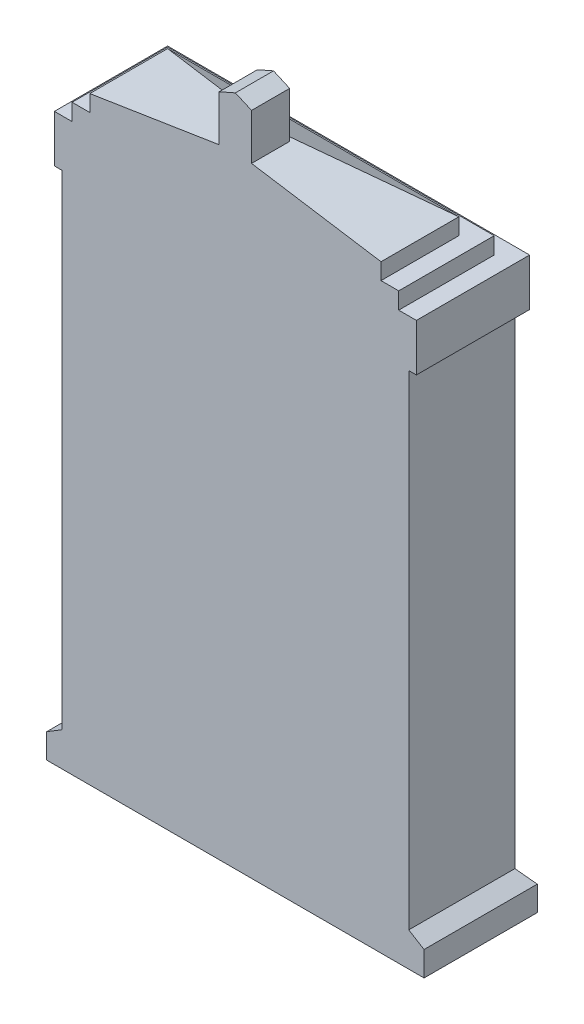
from build123d import *

# Parameters (mm, degrees)
BOSS_EXTRUDE1_DEPTH             = 7.62
SKETCH3_W                       = 9.144
SKETCH3_H                       = 33.984735974
CUT_EXTRUDE3_DEPTH              = 1.27
SKETCH2_W                       = 6.726332881
SKETCH2_H                       = 7.259111723
SKETCH2_H_2                     = 7.259111722
SKETCH2_W_2                     = 1.903444294
SKETCH2_H_3                     = 3.394508427
SKETCH2_W_3                     = 1.903444293
SKETCH2_H_4                     = 3.394508426
CUT_EXTRUDE4_DEPTH              = 2.032
SKETCH5_W                       = 4.686975047
SKETCH5_H                       = 6.157621802
BOSS_EXTRUDE3_DEPTH             = 0.508
SKETCH8_W                       = 27.088929776
SKETCH8_H                       = 1.771956064
BOSS_EXTRUDE4_DEPTH             = 0.508
BOSS_EXTRUDE5_REACH             = 15.544
BOSS_EXTRUDE5_DIRECTION_2_REACH = 15.544
SKETCH10_W                      = 25.989428986
SKETCH10_H                      = 3.393956474
BOSS_EXTRUDE6_DEPTH             = 0.508
SKETCH11_W                      = 23.449428986
SKETCH11_H                      = 9.188805721
CUT_EXTRUDE7_DEPTH              = 0.762
SKETCH12_W                      = 20.909428986
SKETCH12_H                      = 7.410646335
CUT_EXTRUDE8_DEPTH              = 1.27
SKETCH14_W                      = 20.909428986
SKETCH14_H                      = 4.107322124
CUT_EXTRUDE9_DEPTH              = 3.695288508
BOSS_EXTRUDE8_DEPTH             = 2.73742
SKETCH17_W                      = 24.973428986
SKETCH17_H                      = 2.377956474
CUT_EXTRUDE11_DEPTH             = 0.508
CUT_EXTRUDE12_DEPTH             = 0.508
CUT_EXTRUDE13_DEPTH             = 0.254


with BuildPart() as part:
    # Sketch1 → Boss-Extrude1 (new body)
    with BuildSketch(Plane.XY):
        Polygon((12.446, -21.688097012), (13.544464888, -22.358043936), (13.544464888, -24.13), (-13.544464888, -24.13), (-13.544464888, -22.358043936), (-12.446, -21.688097012), (-12.446, 13.088471905), (-12.994714493, 13.088471905), (-12.994714493, 16.482428379), (-11.724714493, 16.482428379), (-11.724714493, 17.683564676), (-10.454714493, 17.683564676), (-10.454714493, 18.85994662), (0, 20.505728027), (10.454714493, 18.85994662), (10.454714493, 17.683564676), (11.724714493, 17.683564676), (11.724714493, 16.482428379), (12.994714493, 16.482428379), (12.994714493, 13.088471905), (12.446, 13.088471905), align=None)
    extrude(amount=BOSS_EXTRUDE1_DEPTH)

    # Sketch3 → Cut-Extrude3 (cut)
    with BuildSketch(Plane.XY):
        with Locations((-5.08, -4.695729099)):
            Rectangle(SKETCH3_W, SKETCH3_H)
        with Locations((5.08, -4.695729099)):
            Rectangle(SKETCH3_W, SKETCH3_H)
    extrude(amount=CUT_EXTRUDE3_DEPTH, mode=Mode.SUBTRACT)

    # Sketch2 → Cut-Extrude4 (cut)
    with BuildSketch(Plane.XY):
        with Locations((-4.97621445, -16.916150366)):
            Rectangle(SKETCH2_W, SKETCH2_H)
        with Locations((-4.97621445, -8.768038644)):
            Rectangle(SKETCH2_W, SKETCH2_H_2)
        with Locations((-4.97621445, -0.619926922)):
            Rectangle(SKETCH2_W, SKETCH2_H)
        with Locations((2.564770156, 9.447591579)):
            Rectangle(SKETCH2_W_2, SKETCH2_H_3)
        with Locations((4.97621445, 9.447591579)):
            Rectangle(SKETCH2_W_3, SKETCH2_H_3)
        with Locations((4.97621445, -0.619926922)):
            Rectangle(SKETCH2_W, SKETCH2_H)
        with Locations((4.97621445, -8.768038644)):
            Rectangle(SKETCH2_W, SKETCH2_H_2)
        with Locations((4.97621445, -16.916150366)):
            Rectangle(SKETCH2_W, SKETCH2_H)
        with Locations((7.387658743, 9.447591579)):
            Rectangle(SKETCH2_W_2, SKETCH2_H_3)
        with Locations((-2.564770156, 5.595883153)):
            Rectangle(SKETCH2_W_2, SKETCH2_H_4)
        with Locations((-4.97621445, 5.595883153)):
            Rectangle(SKETCH2_W_3, SKETCH2_H_4)
        with Locations((-7.387658743, 5.595883153)):
            Rectangle(SKETCH2_W_2, SKETCH2_H_4)
        with Locations((-7.387658743, 9.447591579)):
            Rectangle(SKETCH2_W_2, SKETCH2_H_3)
        with Locations((7.387658743, 5.595883153)):
            Rectangle(SKETCH2_W_2, SKETCH2_H_4)
        with Locations((4.97621445, 5.595883153)):
            Rectangle(SKETCH2_W_3, SKETCH2_H_4)
        with Locations((2.564770156, 5.595883153)):
            Rectangle(SKETCH2_W_2, SKETCH2_H_4)
        with Locations((-4.97621445, 9.447591579)):
            Rectangle(SKETCH2_W_3, SKETCH2_H_3)
        with Locations((-2.564770156, 9.447591579)):
            Rectangle(SKETCH2_W_2, SKETCH2_H_3)
    extrude(amount=CUT_EXTRUDE4_DEPTH, mode=Mode.SUBTRACT)

    # Sketch5 → Boss-Extrude3 (add)
    with BuildSketch(Plane(origin=(0, 0, 2.032), x_dir=(-1, 0, 0), z_dir=(0, 0, -1))):
        with Locations((-4.97621445, -0.619926921)):
            Rectangle(SKETCH5_W, SKETCH5_H)
    extrude(amount=BOSS_EXTRUDE3_DEPTH)

    # Sketch8 → Boss-Extrude4 (add)
    with BuildSketch(Plane(origin=(0, 0, 0), x_dir=(-1, 0, 0), z_dir=(0, 0, -1))):
        with Locations((0, -23.244021968)):
            Rectangle(SKETCH8_W, SKETCH8_H)
    extrude(amount=BOSS_EXTRUDE4_DEPTH)

    # Boss-Extrude5: up to this face of the body (flat: up to its plane)
    boss_extrude5_end = Plane(part.part.faces().sort_by_distance((12.995232444, -22.023070474, 3.81))[0])
    # Sketch9 → Boss-Extrude5 (add, up to the picked face)
    with BuildSketch(Plane(origin=(0, 0, 0), x_dir=(0, 0, -1), z_dir=(1, 0, 0)), mode=Mode.PRIVATE) as boss_extrude5_sk1:
        Polygon((0.508, -22.358043936), (0, -21.688097012), (0, -22.358043936), align=None)
    boss_extrude5_tool1 = split(extrude(boss_extrude5_sk1.sketch, amount=BOSS_EXTRUDE5_REACH, mode=Mode.PRIVATE), bisect_by=boss_extrude5_end, keep=Keep.BOTH, mode=Mode.PRIVATE)
    add(boss_extrude5_tool1.solids().sort_by(Axis((0, -22.134728, -0.169333), (1, 0, 0)))[0])

    # Boss-Extrude5 direction 2: up to this face of the body (flat: up to its plane)
    boss_extrude5_direction_2_end = Plane(part.part.faces().sort_by_distance((-12.995232444, -22.023070474, 3.81))[0])
    # Sketch9 → Boss-Extrude5 direction 2 (add, up to the picked face)
    with BuildSketch(Plane(origin=(0, 0, 0), x_dir=(0, 0, -1), z_dir=(1, 0, 0)), mode=Mode.PRIVATE) as boss_extrude5_direction_2_sk1:
        Polygon((0.508, -22.358043936), (0, -21.688097012), (0, -22.358043936), align=None)
    boss_extrude5_direction_2_tool1 = split(extrude(boss_extrude5_direction_2_sk1.sketch, amount=-BOSS_EXTRUDE5_DIRECTION_2_REACH, mode=Mode.PRIVATE), bisect_by=boss_extrude5_direction_2_end, keep=Keep.BOTH, mode=Mode.PRIVATE)
    add(boss_extrude5_direction_2_tool1.solids().sort_by(Axis((0, -22.134728, -0.169333), (-1, 0, 0)))[0])

    # Sketch10 → Boss-Extrude6 (add)
    with BuildSketch(Plane(origin=(0, 0, 0), x_dir=(-1, 0, 0), z_dir=(0, 0, -1))):
        with Locations((0, 14.785450142)):
            Rectangle(SKETCH10_W, SKETCH10_H)
    extrude(amount=BOSS_EXTRUDE6_DEPTH)

    # Sketch11 → Cut-Extrude7 (cut)
    with BuildSketch(Plane(origin=(0, 0, 0), x_dir=(-1, 0, 0), z_dir=(0, 0, -1))):
        with Locations((0, 21.07683124)):
            Rectangle(SKETCH11_W, SKETCH11_H)
    extrude(amount=-CUT_EXTRUDE7_DEPTH, mode=Mode.SUBTRACT)

    # Sketch12 → Cut-Extrude8 (cut)
    with BuildSketch(Plane(origin=(0, 0, 0.762), x_dir=(-1, 0, 0), z_dir=(0, 0, -1))):
        with Locations((0, 21.388887844)):
            Rectangle(SKETCH12_W, SKETCH12_H)
    extrude(amount=-CUT_EXTRUDE8_DEPTH, mode=Mode.SUBTRACT)

    # Sketch14 → Cut-Extrude9 (cut, through all)
    with BuildSketch(Plane(origin=(0, 13.265078155, -7.658596443), x_dir=(1, 0, 0), z_dir=(0, -0.866025404, 0.5))):
        with Locations((0, 13.243397992)):
            Rectangle(SKETCH14_W, SKETCH14_H)
    extrude(amount=-CUT_EXTRUDE9_DEPTH, mode=Mode.SUBTRACT)

    # Sketch15 → Boss-Extrude8 (add)
    with BuildSketch(Plane.XY.offset(7.62)):
        Polygon((1.159221801, 23.619819437), (1.159221801, 19.582815565), (-1.159221801, 19.582815565), (-1.159221801, 23.619819437), (0, 24.13), align=None)
    extrude(amount=-BOSS_EXTRUDE8_DEPTH)

    # Sketch17 → Cut-Extrude11 (cut)
    with BuildSketch(Plane(origin=(0, 0, -0.508), x_dir=(-1, 0, 0), z_dir=(0, 0, -1))):
        with Locations((0, 14.785450142)):
            Rectangle(SKETCH17_W, SKETCH17_H)
    extrude(amount=-CUT_EXTRUDE11_DEPTH, mode=Mode.SUBTRACT)

    # Sketch19 → Cut-Extrude12 (cut)
    with BuildSketch(Plane(origin=(0, 0, 1.524), x_dir=(-1, 0, 0), z_dir=(0, 0, -1))):
        Polygon((-5.977526797, 1.270542493), (-3.764099503, 1.270542493), (-3.764099503, 0.743535995), (-5.397819648, 0.743535995), (-5.397819648, -0.415878302), (-3.816800152, -0.415878302), (-3.816800152, -0.942884801), (-5.397819648, -0.942884801), (-5.397819648, -2.102299098), (-3.711398853, -2.102299098), (-3.711398853, -2.629305597), (-5.977526797, -2.629305597), align=None)
    extrude(amount=-CUT_EXTRUDE12_DEPTH, mode=Mode.SUBTRACT)

    # Sketch18 → Cut-Extrude13 (cut)
    with BuildSketch(Plane(origin=(0, 0, 0), x_dir=(-1, 0, 0), z_dir=(0, 0, -1))):
        Polygon((-7.010421604, 15.726233572), (-6.732508021, 15.726233572), (-6.732508021, 13.776309527), (-7.022361595, 13.776309527), (-7.022361595, 15.293923553), (-7.616479077, 14.54046895), (-7.667944556, 14.54046895), (-8.260826867, 15.293923553), (-8.260826867, 13.776309527), (-8.550680441, 13.776309527), (-8.550680441, 15.726233572), (-8.267826172, 15.726233572), (-7.639947336, 14.927901071), align=None)
        Polygon((-5.687141224, 15.752583897), (-5.489925511, 15.752583897), (-4.624482026, 13.776309527), (-4.907748019, 13.776309527), (-5.159723001, 14.356016675), (-6.009109257, 14.356016675), (-6.261495963, 13.776309527), (-6.548055746, 13.776309527), align=None)
        Polygon((-5.268006368, 14.619519924), (-5.586268886, 15.326038012), (-5.894238309, 14.619519924), align=None, mode=Mode.SUBTRACT)
        with BuildLine():
            Line((-2.779959281, 14.22426505), (-2.779959281, 13.908061151))
            add(Edge.make_bspline(
                [(-2.779959281, 13.908061151), (-2.805589179, 13.895330544), (-2.857158599, 13.869715536), (-2.937996897, 13.838054552), (-3.021516615, 13.81059668), (-3.108061694, 13.788492302), (-3.19756462, 13.771183254), (-3.289950019, 13.758948039), (-3.38520171, 13.751329729), (-3.449682299, 13.750420159), (-3.48236013, 13.749959202)],
                knots=[0, 0, 0, 0, 0.944453899, 1.900317374, 2.863243185, 3.845757078, 4.847281353, 5.871338754, 6.921225227, 8, 8, 8, 8], degree=3))
            add(Edge.make_bspline(
                [(-3.48236013, 13.749959202), (-3.508859854, 13.75033969), (-3.560835679, 13.751085969), (-3.637140795, 13.757378383), (-3.710416173, 13.767668027), (-3.78074219, 13.781907013), (-3.847932172, 13.80056787), (-3.912227459, 13.822644776), (-3.973239146, 13.849596933), (-4.031344549, 13.880380393), (-4.086064557, 13.915251879), (-4.138236107, 13.952675406), (-4.187188511, 13.993578871), (-4.233515903, 14.03731991), (-4.276893545, 14.084231515), (-4.316680473, 14.134832668), (-4.354334612, 14.187764136), (-4.388408296, 14.243854855), (-4.419013129, 14.301894564), (-4.44621321, 14.361378559), (-4.468073288, 14.422432265), (-4.486894867, 14.484319099), (-4.501284071, 14.547476891), (-4.511503252, 14.611706557), (-4.517936295, 14.677167212), (-4.518696589, 14.721200888), (-4.519080726, 14.743448796)],
                knots=[0, 0, 0, 0, 1.186631646, 2.327426461, 3.426117396, 4.498922039, 5.538244665, 6.54707883, 7.540593583, 8.522192574, 9.489037127, 10.444325353, 11.395750131, 12.343554816, 13.296150188, 14.254123699, 15.224419991, 16.20368787, 17.19071747, 18.161772664, 19.13008132, 20.092618322, 21.057291924, 22.028347119, 23.003827162, 24, 24, 24, 24], degree=3))
            add(Edge.make_bspline(
                [(-4.519080726, 14.743448796), (-4.518328653, 14.778365729), (-4.516847404, 14.847136502), (-4.501621811, 14.947826707), (-4.478975503, 15.044709392), (-4.44580542, 15.136956836), (-4.403512553, 15.225255545), (-4.351299046, 15.308703076), (-4.290429347, 15.388570262), (-4.220287721, 15.462527586), (-4.144119693, 15.530761575), (-4.061924143, 15.589828526), (-3.975824692, 15.640475038), (-3.884956289, 15.681159588), (-3.790144539, 15.713841439), (-3.690559081, 15.736044551), (-3.586791917, 15.750106508), (-3.516167717, 15.751749507), (-3.48030151, 15.752583897)],
                knots=[0, 0, 0, 0, 1.03662429, 2.041687189, 3.018769806, 3.988602689, 4.947852564, 5.922038348, 6.90799648, 7.926239048, 8.94578695, 9.941643834, 10.928377303, 11.908322743, 12.894719184, 13.902631409, 14.934860088, 16, 16, 16, 16], degree=3))
            add(Edge.make_bspline(
                [(-3.48030151, 15.752583897), (-3.454620447, 15.752093525), (-3.402469662, 15.751097722), (-3.323286245, 15.743297857), (-3.242061515, 15.730936304), (-3.158799504, 15.713512914), (-3.073482645, 15.691210687), (-2.986048961, 15.663792237), (-2.896375155, 15.631936299), (-2.836670086, 15.607107553), (-2.806309606, 15.594481947)],
                knots=[0, 0, 0, 0, 0.884314381, 1.795785806, 2.737645304, 3.7128219, 4.723955122, 5.773413228, 6.867763749, 8, 8, 8, 8], degree=3))
            Line((-2.806309606, 15.594481947), (-2.806309606, 15.304628373))
            add(Edge.make_bspline(
                [(-2.806309606, 15.304628373), (-2.834155644, 15.319341361), (-2.88889075, 15.348261703), (-2.972455157, 15.385855139), (-3.055516618, 15.417534157), (-3.138105184, 15.443670994), (-3.220203032, 15.463956459), (-3.301901765, 15.478359209), (-3.383205152, 15.487395326), (-3.437322347, 15.488520768), (-3.464244281, 15.489080647)],
                knots=[0, 0, 0, 0, 1.094437468, 2.151262971, 3.18245778, 4.182693089, 5.160299121, 6.119424509, 7.064461304, 8, 8, 8, 8], degree=3))
            add(Edge.make_bspline(
                [(-3.464244281, 15.489080647), (-3.49117494, 15.488476076), (-3.543988844, 15.487290448), (-3.621448729, 15.477133291), (-3.69547079, 15.460704197), (-3.766259873, 15.437795316), (-3.833099195, 15.407390717), (-3.896771009, 15.371061928), (-3.956438841, 15.327427718), (-4.012559502, 15.278423217), (-4.063574322, 15.224414211), (-4.107577009, 15.166036166), (-4.145661718, 15.104824244), (-4.176009576, 15.039741195), (-4.20018561, 14.97154194), (-4.216799973, 14.899852052), (-4.227545292, 14.825021765), (-4.228660086, 14.773954371), (-4.229227152, 14.747977758)],
                knots=[0, 0, 0, 0, 1.084756759, 2.127324043, 3.141584004, 4.136607041, 5.119197986, 6.095231591, 7.085217128, 8.092336669, 9.093838517, 10.072640928, 11.033390994, 11.993185724, 12.960343823, 13.943510343, 14.953918928, 16, 16, 16, 16], degree=3))
            add(Edge.make_bspline(
                [(-4.229227152, 14.747977758), (-4.228677751, 14.721723448), (-4.227600383, 14.670239148), (-4.21668733, 14.595069662), (-4.200810704, 14.523223476), (-4.176326764, 14.455473161), (-4.14637067, 14.39067997), (-4.109201969, 14.329645475), (-4.065041758, 14.272467508), (-4.015033405, 14.219203589), (-3.959770345, 14.170678312), (-3.899852642, 14.128714743), (-3.836407146, 14.092813226), (-3.769011969, 14.06419405), (-3.698064823, 14.041356588), (-3.623396298, 14.024831652), (-3.544773568, 14.015401692), (-3.491168556, 14.014117386), (-3.463832557, 14.013462451)],
                knots=[0, 0, 0, 0, 1.058669431, 2.076034553, 3.059369532, 4.022712324, 4.976537028, 5.935796217, 6.899457311, 7.886760787, 8.879717062, 9.861491389, 10.833470646, 11.815869532, 12.810631001, 13.837179062, 14.89706449, 16, 16, 16, 16], degree=3))
            add(Edge.make_bspline(
                [(-3.463832557, 14.013462451), (-3.434709975, 14.014097668), (-3.376436031, 14.01536873), (-3.289445992, 14.02562104), (-3.203027985, 14.042106763), (-3.117176971, 14.065299919), (-3.031745981, 14.095049487), (-2.946818713, 14.131516794), (-2.862186487, 14.174125138), (-2.807600589, 14.207410133), (-2.779959281, 14.22426505)],
                knots=[0, 0, 0, 0, 0.963461728, 1.927875573, 2.894254865, 3.872502036, 4.867814554, 5.885128361, 6.929067366, 8, 8, 8, 8], degree=3))
        make_face()
        with BuildLine():
            Line((-1.409742384, 14.724921224), (-0.750984261, 14.724921224))
            Line((-0.750984261, 14.724921224), (-0.750984261, 13.919589418))
            add(Edge.make_bspline(
                [(-0.750984261, 13.919589418), (-0.780615182, 13.90592374), (-0.839092269, 13.878954311), (-0.928523072, 13.845041219), (-1.017439237, 13.815519118), (-1.106401697, 13.791703523), (-1.195173833, 13.772956716), (-1.283745258, 13.760052218), (-1.372094229, 13.75116143), (-1.43099318, 13.750359416), (-1.460384415, 13.749959202)],
                knots=[0, 0, 0, 0, 1.064601606, 2.1010079, 3.119372398, 4.121083354, 5.10491149, 6.078480835, 7.04114048, 8, 8, 8, 8], degree=3))
            add(Edge.make_bspline(
                [(-1.460384415, 13.749959202), (-1.499534506, 13.750826891), (-1.576005954, 13.75252174), (-1.687646243, 13.765795428), (-1.793173583, 13.788067739), (-1.892904401, 13.818742331), (-1.98640283, 13.858912598), (-2.073985965, 13.907753244), (-2.155414416, 13.965638601), (-2.229995169, 14.031943112), (-2.297421828, 14.104289071), (-2.35550011, 14.182206887), (-2.405498634, 14.263577683), (-2.44584751, 14.349421836), (-2.478081547, 14.439192548), (-2.499776336, 14.533477755), (-2.514018625, 14.631575384), (-2.515634751, 14.698382368), (-2.516456031, 14.732332253)],
                knots=[0, 0, 0, 0, 1.161284433, 2.268324228, 3.329620089, 4.357306638, 5.358676107, 6.343013956, 7.327048601, 8.316426186, 9.298909655, 10.255747547, 11.194958291, 12.127472954, 13.064996478, 14.019014713, 14.993305488, 16, 16, 16, 16], degree=3))
            add(Edge.make_bspline(
                [(-2.516456031, 14.732332253), (-2.515653728, 14.768064519), (-2.514073573, 14.838440027), (-2.499581389, 14.941536098), (-2.476819538, 15.04027276), (-2.443830155, 15.134011201), (-2.402920395, 15.223734362), (-2.351049335, 15.308006208), (-2.29094581, 15.388218531), (-2.22178957, 15.462626474), (-2.14639441, 15.530854469), (-2.064647399, 15.589801972), (-1.978884219, 15.640570071), (-1.887981075, 15.681234004), (-1.792862742, 15.713829634), (-1.692741322, 15.736090303), (-1.588007258, 15.750135586), (-1.516562075, 15.751757316), (-1.480147158, 15.752583897)],
                knots=[0, 0, 0, 0, 1.054239936, 2.076349507, 3.066852376, 4.040560888, 5.004835511, 5.971965235, 6.955584564, 7.958993552, 8.965937392, 9.952106236, 10.928995132, 11.902636222, 12.886522476, 13.891900433, 14.925522102, 16, 16, 16, 16], degree=3))
            add(Edge.make_bspline(
                [(-1.480147158, 15.752583897), (-1.453366318, 15.751999705), (-1.40050054, 15.750846501), (-1.322120293, 15.74257684), (-1.246067568, 15.72804925), (-1.183758027, 15.711418844), (-1.133530536, 15.694750498), (-1.093375266, 15.680068693), (-1.050970535, 15.662521003), (-1.005990813, 15.64324493), (-0.958742426, 15.621458146), (-0.909170777, 15.596918352), (-0.857125555, 15.570338393), (-0.821770599, 15.551445753), (-0.80368491, 15.541781297)],
                knots=[0, 0, 0, 0, 1.344637091, 2.654333741, 3.951808607, 5.228901813, 5.889193497, 6.608649239, 7.375177798, 8.193164664, 9.065757763, 9.987239507, 10.970380306, 12, 12, 12, 12], degree=3))
            Line((-0.80368491, 15.541781297), (-0.80368491, 15.278278048))
            add(Edge.make_bspline(
                [(-0.80368491, 15.278278048), (-0.832037793, 15.295093411), (-0.887742758, 15.328130588), (-0.973311085, 15.370994458), (-1.058558601, 15.407318841), (-1.143768246, 15.43727864), (-1.228845165, 15.460265148), (-1.31371418, 15.476866969), (-1.398370828, 15.487161721), (-1.454866685, 15.488442295), (-1.483029225, 15.489080647)],
                knots=[0, 0, 0, 0, 1.097876068, 2.156999319, 3.185361631, 4.183051658, 5.16346459, 6.118388253, 7.06203801, 8, 8, 8, 8], degree=3))
            add(Edge.make_bspline(
                [(-1.483029225, 15.489080647), (-1.508723621, 15.488462206), (-1.559210598, 15.487247028), (-1.633451593, 15.477223804), (-1.704364147, 15.460193896), (-1.772533395, 15.43721512), (-1.837312293, 15.406941457), (-1.899181023, 15.370059262), (-1.957569304, 15.326179731), (-2.012487403, 15.276640128), (-2.062493201, 15.222255832), (-2.106242051, 15.163998623), (-2.143680375, 15.102922631), (-2.173712561, 15.038433048), (-2.198053876, 14.971333581), (-2.213995894, 14.900752692), (-2.224966184, 14.827509581), (-2.22605066, 14.777526923), (-2.226602457, 14.752094997)],
                knots=[0, 0, 0, 0, 1.056215917, 2.075361086, 3.073160535, 4.051086936, 5.028133745, 6.007524377, 7.007475718, 8.026308381, 9.04476591, 10.040200902, 11.017671317, 11.984495909, 12.96080912, 13.946325763, 14.955059762, 16, 16, 16, 16], degree=3))
            add(Edge.make_bspline(
                [(-2.226602457, 14.752094997), (-2.22605147, 14.725567657), (-2.22497082, 14.673539534), (-2.214056592, 14.597402714), (-2.198082154, 14.524707233), (-2.174427695, 14.455792363), (-2.143657365, 14.391005363), (-2.10696656, 14.329463455), (-2.062913913, 14.272128107), (-2.012953667, 14.218771759), (-1.957400335, 14.170732662), (-1.897609275, 14.128529221), (-1.833746058, 14.093034201), (-1.766389102, 14.063602713), (-1.695057493, 14.040868558), (-1.619890212, 14.02496173), (-1.540782792, 14.015349672), (-1.486762135, 14.014100811), (-1.459149243, 14.013462451)],
                knots=[0, 0, 0, 0, 1.064067175, 2.08695707, 3.081189305, 4.048018083, 5.004116259, 5.955441868, 6.918370985, 7.900442779, 8.884520914, 9.861092858, 10.832727358, 11.81210731, 12.806843005, 13.83216257, 14.891900563, 16, 16, 16, 16], degree=3))
            add(Edge.make_bspline(
                [(-1.459149243, 14.013462451), (-1.445141546, 14.013701454), (-1.416393984, 14.014191953), (-1.372329132, 14.018305453), (-1.326219234, 14.023704999), (-1.278275795, 14.032873922), (-1.228189935, 14.043241419), (-1.1761558, 14.056858078), (-1.121843312, 14.071636538), (-1.085386064, 14.083822665), (-1.066776436, 14.090043083)],
                knots=[0, 0, 0, 0, 0.837330565, 1.718427446, 2.644603876, 3.611922477, 4.635483658, 5.702208386, 6.827090645, 8, 8, 8, 8], degree=3))
            Line((-1.066776436, 14.090043083), (-1.040837835, 14.098277559))
            Line((-1.040837835, 14.098277559), (-1.040837835, 14.461417975))
            Line((-1.040837835, 14.461417975), (-1.409742384, 14.461417975))
            Line((-1.409742384, 14.461417975), (-1.409742384, 14.724921224))
        make_face()
        with BuildLine():
            Line((-0.329379062, 13.776309527), (-0.329379062, 15.726233572))
            Line((-0.329379062, 15.726233572), (0.159748845, 15.726233572))
            add(Edge.make_bspline(
                [(0.159748845, 15.726233572), (0.183778592, 15.725700655), (0.230694458, 15.724660185), (0.299151038, 15.718274639), (0.363826181, 15.706613682), (0.424739634, 15.690701321), (0.482004612, 15.670298977), (0.53489056, 15.644259263), (0.584733566, 15.614951873), (0.629817633, 15.580134128), (0.670775592, 15.54202904), (0.706227973, 15.500187382), (0.736910684, 15.455475852), (0.760877857, 15.406859641), (0.780650894, 15.355587815), (0.794123687, 15.300816913), (0.801911494, 15.242821024), (0.803084475, 15.203093943), (0.80368491, 15.18275812)],
                knots=[0, 0, 0, 0, 1.213482164, 2.369212066, 3.467585594, 4.528254993, 5.545448104, 6.531084455, 7.500904017, 8.460067539, 9.401390007, 10.320694869, 11.224084847, 12.132167517, 13.051158872, 13.994087106, 14.973196883, 16, 16, 16, 16], degree=3))
            add(Edge.make_bspline(
                [(0.80368491, 15.18275812), (0.803500055, 15.168746796), (0.803136749, 15.141209558), (0.798707166, 15.100662582), (0.792415504, 15.06150708), (0.782677074, 15.023889526), (0.770989352, 14.987539815), (0.755866003, 14.952871301), (0.738754566, 14.919356887), (0.711707097, 14.877209191), (0.671910635, 14.828339546), (0.614880459, 14.777132832), (0.548200138, 14.734177806), (0.498816462, 14.713093013), (0.473482401, 14.702276414)],
                knots=[0, 0, 0, 0, 0.808746272, 1.589474265, 2.352996596, 3.096892747, 3.831228218, 4.555530078, 5.278660243, 6.002007532, 7.444048878, 8.903237367, 10.411345989, 12, 12, 12, 12], degree=3))
            add(Edge.make_bspline(
                [(0.473482401, 14.702276414), (0.489185605, 14.691278429), (0.52148003, 14.668660522), (0.567457673, 14.62878443), (0.612812957, 14.58322217), (0.650082407, 14.540699939), (0.681017114, 14.502107713), (0.706770815, 14.468020485), (0.735009002, 14.429196562), (0.764700379, 14.385060443), (0.797317375, 14.336628019), (0.832017048, 14.28321887), (0.868896005, 14.224999368), (0.894028947, 14.184352369), (0.907027591, 14.163329924)],
                knots=[0, 0, 0, 0, 0.989758618, 2.035488206, 3.138290431, 4.308676052, 4.954132905, 5.692827411, 6.515283046, 7.433531162, 8.440205653, 9.531486756, 10.723296036, 12, 12, 12, 12], degree=3))
            add(Edge.make_bspline(
                [(0.907027591, 14.163329924), (0.922991903, 14.137469757), (0.952934865, 14.088965945), (0.996310702, 14.021801288), (1.034157657, 13.964616371), (1.058591958, 13.930508334), (1.069658503, 13.915060456)],
                knots=[0, 0, 0, 0, 1.228448071, 2.304100194, 3.231909668, 4, 4, 4, 4], degree=3))
            Line((1.069658503, 13.915060456), (1.17258946, 13.776309527))
            Line((1.17258946, 13.776309527), (0.841563503, 13.776309527))
            Line((0.841563503, 13.776309527), (0.756748394, 13.903943913))
            add(Edge.make_bspline(
                [(0.756748394, 13.903943913), (0.754724032, 13.9071242), (0.749588423, 13.915192278), (0.743791391, 13.922802038), (0.740279441, 13.927412171)],
                knots=[0, 0, 0, 0, 0.788363007, 2, 2, 2, 2], degree=3))
            Line((0.740279441, 13.927412171), (0.68634362, 14.003992803))
            Line((0.68634362, 14.003992803), (0.60029334, 14.145625799))
            Line((0.60029334, 14.145625799), (0.507243755, 14.296728444))
            add(Edge.make_bspline(
                [(0.507243755, 14.296728444), (0.493421469, 14.315802369), (0.466994597, 14.352269868), (0.426314244, 14.402461281), (0.388313868, 14.447099855), (0.351842824, 14.485521688), (0.317575122, 14.518867806), (0.284886549, 14.546880733), (0.25364249, 14.569604307), (0.223244713, 14.589532669), (0.187566308, 14.60364551), (0.144133355, 14.613083866), (0.091123991, 14.618458648), (0.052576693, 14.619147111), (0.031702735, 14.619519924)],
                knots=[0, 0, 0, 0, 1.400374657, 2.677380837, 3.840444198, 4.88527402, 5.825998599, 6.682811393, 7.441781017, 8.123414164, 8.837165704, 9.708162041, 10.758934312, 12, 12, 12, 12], degree=3))
            Line((0.031702735, 14.619519924), (-0.039525487, 14.619519924))
            Line((-0.039525487, 14.619519924), (-0.039525487, 13.776309527))
            Line((-0.039525487, 13.776309527), (-0.329379062, 13.776309527))
        make_face()
        with BuildLine():
            Line((0.042819278, 15.462730322), (-0.039525487, 15.462730322))
            Line((-0.039525487, 15.462730322), (-0.039525487, 14.883023174))
            Line((-0.039525487, 14.883023174), (0.064640641, 14.883023174))
            add(Edge.make_bspline(
                [(0.064640641, 14.883023174), (0.081248016, 14.883069021), (0.113236783, 14.88315733), (0.159101828, 14.884743139), (0.200969211, 14.88768527), (0.238588798, 14.891344594), (0.272351173, 14.895558408), (0.301849396, 14.901847367), (0.327486934, 14.908669032), (0.355982347, 14.918930457), (0.3866077, 14.935521407), (0.419386663, 14.959137442), (0.44751133, 14.987522748), (0.47159744, 15.019691853), (0.490425049, 15.055604798), (0.504174417, 15.094105058), (0.512053322, 15.135092742), (0.513230186, 15.163099611), (0.513831336, 15.17740571)],
                knots=[0, 0, 0, 0, 1.296350897, 2.497003015, 3.581639737, 4.571966247, 5.447707095, 6.235624804, 6.924364436, 7.517477665, 8.595746602, 9.630729097, 10.660987776, 11.702327207, 12.756646574, 13.813846822, 14.883298147, 16, 16, 16, 16], degree=3))
            add(Edge.make_bspline(
                [(0.513831336, 15.17740571), (0.513325468, 15.191590872), (0.512327443, 15.219576665), (0.502918219, 15.260456382), (0.487451901, 15.299080915), (0.466559809, 15.335287339), (0.440207259, 15.367999044), (0.408594601, 15.395826645), (0.372061049, 15.418469141), (0.337600838, 15.43249095), (0.306467929, 15.440930543), (0.279475101, 15.447240222), (0.248760588, 15.451920983), (0.214593662, 15.456200278), (0.176641918, 15.45868601), (0.135218243, 15.461448376), (0.090172252, 15.462469982), (0.059013614, 15.462641288), (0.042819278, 15.462730322)],
                knots=[0, 0, 0, 0, 1.083232434, 2.137100716, 3.18730627, 4.254514202, 5.321309408, 6.384382863, 7.458787847, 8.592815929, 9.214010724, 9.924183374, 10.710779775, 11.587965019, 12.556075927, 13.617698511, 14.761826802, 16, 16, 16, 16], degree=3))
        make_face(mode=Mode.SUBTRACT)
        Polygon((1.383392059, 15.726233572), (2.490105706, 15.726233572), (2.490105706, 15.462730322), (1.673245633, 15.462730322), (1.673245633, 14.883023174), (2.463755381, 14.883023174), (2.463755381, 14.619519924), (1.673245633, 14.619519924), (1.673245633, 14.039812776), (2.516456031, 14.039812776), (2.516456031, 13.776309527), (1.383392059, 13.776309527), align=None)
        with BuildLine():
            Line((3.833972278, 14.724921224), (4.492730401, 14.724921224))
            Line((4.492730401, 14.724921224), (4.492730401, 13.919589418))
            add(Edge.make_bspline(
                [(4.492730401, 13.919589418), (4.46309948, 13.90592374), (4.404622393, 13.878954311), (4.31519159, 13.845041219), (4.226275425, 13.815519118), (4.137312965, 13.791703523), (4.048540829, 13.772956716), (3.959969404, 13.760052218), (3.871620433, 13.75116143), (3.812721482, 13.750359416), (3.783330247, 13.749959202)],
                knots=[0, 0, 0, 0, 1.064601606, 2.1010079, 3.119372398, 4.121083354, 5.10491149, 6.078480835, 7.04114048, 8, 8, 8, 8], degree=3))
            add(Edge.make_bspline(
                [(3.783330247, 13.749959202), (3.744180156, 13.750826891), (3.667708708, 13.75252174), (3.556068419, 13.765795428), (3.450541079, 13.788067739), (3.350810261, 13.818742331), (3.257311832, 13.858912598), (3.169728697, 13.907753244), (3.088300246, 13.965638601), (3.013719493, 14.031943112), (2.946292834, 14.104289071), (2.888214552, 14.182206887), (2.838216027, 14.263577683), (2.797867152, 14.349421836), (2.765633115, 14.439192548), (2.743938326, 14.533477755), (2.729696037, 14.631575384), (2.728079911, 14.698382368), (2.727258631, 14.732332253)],
                knots=[0, 0, 0, 0, 1.161284433, 2.268324228, 3.329620089, 4.357306638, 5.358676107, 6.343013956, 7.327048601, 8.316426186, 9.298909655, 10.255747547, 11.194958291, 12.127472954, 13.064996478, 14.019014713, 14.993305488, 16, 16, 16, 16], degree=3))
            add(Edge.make_bspline(
                [(2.727258631, 14.732332253), (2.728060934, 14.768064519), (2.729641089, 14.838440027), (2.744133273, 14.941536098), (2.766895123, 15.04027276), (2.799884507, 15.134011201), (2.840794267, 15.223734362), (2.892665327, 15.308006208), (2.952768852, 15.388218531), (3.021925092, 15.462626474), (3.097320252, 15.530854469), (3.179067263, 15.589801972), (3.264830443, 15.640570071), (3.355733587, 15.681234004), (3.45085192, 15.713829634), (3.55097334, 15.736090303), (3.655707404, 15.750135586), (3.727152587, 15.751757316), (3.763567504, 15.752583897)],
                knots=[0, 0, 0, 0, 1.054239936, 2.076349507, 3.066852376, 4.040560888, 5.004835511, 5.971965235, 6.955584564, 7.958993552, 8.965937392, 9.952106236, 10.928995132, 11.902636222, 12.886522476, 13.891900433, 14.925522102, 16, 16, 16, 16], degree=3))
            add(Edge.make_bspline(
                [(3.763567504, 15.752583897), (3.790348343, 15.751999705), (3.843214122, 15.750846501), (3.921594369, 15.74257684), (3.997647094, 15.72804925), (4.059956635, 15.711418844), (4.110184126, 15.694750498), (4.150339395, 15.680068693), (4.192744127, 15.662521003), (4.237723849, 15.64324493), (4.284972236, 15.621458146), (4.334543885, 15.596918352), (4.386589107, 15.570338393), (4.421944063, 15.551445753), (4.440029751, 15.541781297)],
                knots=[0, 0, 0, 0, 1.344637091, 2.654333741, 3.951808607, 5.228901813, 5.889193497, 6.608649239, 7.375177798, 8.193164664, 9.065757763, 9.987239507, 10.970380306, 12, 12, 12, 12], degree=3))
            Line((4.440029751, 15.541781297), (4.440029751, 15.278278048))
            add(Edge.make_bspline(
                [(4.440029751, 15.278278048), (4.411676869, 15.295093411), (4.355971904, 15.328130588), (4.270403577, 15.370994458), (4.185156061, 15.407318841), (4.099946416, 15.43727864), (4.014869497, 15.460265148), (3.930000482, 15.476866969), (3.845343834, 15.487161721), (3.788847977, 15.488442295), (3.760685437, 15.489080647)],
                knots=[0, 0, 0, 0, 1.097876068, 2.156999319, 3.185361631, 4.183051658, 5.16346459, 6.118388253, 7.06203801, 8, 8, 8, 8], degree=3))
            add(Edge.make_bspline(
                [(3.760685437, 15.489080647), (3.734991041, 15.488462206), (3.684504064, 15.487247028), (3.610263069, 15.477223804), (3.539350515, 15.460193896), (3.471181267, 15.43721512), (3.406402369, 15.406941457), (3.344533639, 15.370059262), (3.286145358, 15.326179731), (3.231227259, 15.276640128), (3.18122146, 15.222255832), (3.137472611, 15.163998623), (3.100034287, 15.102922631), (3.070002101, 15.038433048), (3.045660786, 14.971333581), (3.029718768, 14.900752692), (3.018748478, 14.827509581), (3.017664002, 14.777526923), (3.017112205, 14.752094997)],
                knots=[0, 0, 0, 0, 1.056215917, 2.075361086, 3.073160535, 4.051086936, 5.028133745, 6.007524377, 7.007475718, 8.026308381, 9.04476591, 10.040200902, 11.017671317, 11.984495909, 12.96080912, 13.946325763, 14.955059762, 16, 16, 16, 16], degree=3))
            add(Edge.make_bspline(
                [(3.017112205, 14.752094997), (3.017663191, 14.725567657), (3.018743842, 14.673539534), (3.02965807, 14.597402714), (3.045632508, 14.524707233), (3.069286967, 14.455792363), (3.100057297, 14.391005363), (3.136748101, 14.329463455), (3.180800749, 14.272128107), (3.230760995, 14.218771759), (3.286314327, 14.170732662), (3.346105387, 14.128529221), (3.409968604, 14.093034201), (3.47732556, 14.063602713), (3.548657169, 14.040868558), (3.62382445, 14.02496173), (3.70293187, 14.015349672), (3.756952527, 14.014100811), (3.784565419, 14.013462451)],
                knots=[0, 0, 0, 0, 1.064067175, 2.08695707, 3.081189305, 4.048018083, 5.004116259, 5.955441868, 6.918370985, 7.900442779, 8.884520914, 9.861092858, 10.832727358, 11.81210731, 12.806843005, 13.83216257, 14.891900563, 16, 16, 16, 16], degree=3))
            add(Edge.make_bspline(
                [(3.784565419, 14.013462451), (3.798573116, 14.013701454), (3.827320678, 14.014191953), (3.87138553, 14.018305453), (3.917495428, 14.023704999), (3.965438867, 14.032873922), (4.015524727, 14.043241419), (4.067558862, 14.056858078), (4.12187135, 14.071636538), (4.158328598, 14.083822665), (4.176938226, 14.090043083)],
                knots=[0, 0, 0, 0, 0.837330565, 1.718427446, 2.644603876, 3.611922477, 4.635483658, 5.702208386, 6.827090645, 8, 8, 8, 8], degree=3))
            Line((4.176938226, 14.090043083), (4.202876827, 14.098277559))
            Line((4.202876827, 14.098277559), (4.202876827, 14.461417975))
            Line((4.202876827, 14.461417975), (3.833972278, 14.461417975))
            Line((3.833972278, 14.461417975), (3.833972278, 14.724921224))
        make_face()
        with BuildLine():
            add(Edge.make_bspline(
                [(5.871181774, 15.752583897), (5.907861964, 15.751700663), (5.979818627, 15.749967996), (6.085480631, 15.736725868), (6.186286958, 15.713879818), (6.282715492, 15.682794714), (6.374121373, 15.641983429), (6.461236868, 15.593038932), (6.542905753, 15.53394844), (6.619399259, 15.467263887), (6.689323835, 15.394123787), (6.749899087, 15.315051265), (6.802045849, 15.231900982), (6.844033681, 15.143825769), (6.876810781, 15.051209632), (6.900137303, 14.954229344), (6.914595019, 14.852579959), (6.916161637, 14.78329769), (6.916960295, 14.747977758)],
                knots=[0, 0, 0, 0, 1.085734744, 2.129919485, 3.146158958, 4.141919608, 5.124160251, 6.104853502, 7.094819842, 8.102716274, 9.105711827, 10.084964819, 11.046663516, 12.006188355, 12.967406306, 13.949890609, 14.954859237, 16, 16, 16, 16], degree=3))
            add(Edge.make_bspline(
                [(6.916960295, 14.747977758), (6.916208342, 14.712651345), (6.91473293, 14.643337213), (6.899626536, 14.541893195), (6.876426861, 14.444968005), (6.84337117, 14.35270721), (6.800655327, 14.265199254), (6.748367505, 14.182567589), (6.687074203, 14.104148956), (6.616605916, 14.031552143), (6.539162229, 13.965659862), (6.456463456, 13.907387999), (6.36833499, 13.858670481), (6.275246201, 13.819145017), (6.177387974, 13.788041573), (6.074693879, 13.7659664), (5.966921276, 13.752520181), (5.89345431, 13.750824751), (5.855947993, 13.749959202)],
                knots=[0, 0, 0, 0, 1.039499297, 2.039606786, 3.012861125, 3.970247594, 4.919075892, 5.874302227, 6.844363355, 7.844617788, 8.847920516, 9.834465204, 10.818465763, 11.807003047, 12.807690022, 13.837300263, 14.895899672, 16, 16, 16, 16], degree=3))
            add(Edge.make_bspline(
                [(5.855947993, 13.749959202), (5.8202252, 13.750835172), (5.750040432, 13.752556195), (5.647039774, 13.765939636), (5.548627362, 13.788173926), (5.45469458, 13.819136183), (5.365216024, 13.858798141), (5.28039451, 13.90752876), (5.200629601, 13.965828581), (5.125788256, 14.031561323), (5.057601463, 14.104061469), (4.998076545, 14.181995614), (4.947988491, 14.264655819), (4.90635176, 14.351372362), (4.874893884, 14.442966132), (4.851514069, 14.538675544), (4.837830954, 14.639022983), (4.836142444, 14.707450289), (4.835284625, 14.742213625)],
                knots=[0, 0, 0, 0, 1.077168657, 2.116319164, 3.126500571, 4.116067885, 5.094473949, 6.073553975, 7.060477364, 8.069385915, 9.073826764, 10.057341621, 11.021370122, 11.984135933, 12.952845072, 13.93670828, 14.951779506, 16, 16, 16, 16], degree=3))
            add(Edge.make_bspline(
                [(4.835284625, 14.742213625), (4.836064989, 14.77794859), (4.83759599, 14.848057303), (4.852290953, 14.950684975), (4.874564207, 15.048865771), (4.906761071, 15.142383506), (4.948705263, 15.230779805), (4.999180954, 15.314728191), (5.059381529, 15.393541859), (5.12770195, 15.467249583), (5.203209643, 15.534024065), (5.283994024, 15.593017333), (5.37028604, 15.641969308), (5.460976068, 15.682877574), (5.556900127, 15.713867016), (5.657289543, 15.736729622), (5.76268028, 15.749985452), (5.834501304, 15.751705456), (5.871181774, 15.752583897)],
                knots=[0, 0, 0, 0, 1.058174226, 2.076040427, 3.065354853, 4.037523495, 4.999751247, 5.959320466, 6.934427026, 7.932849937, 8.932398335, 9.916568469, 10.890988045, 11.866594696, 12.859296081, 13.872391529, 14.913386705, 16, 16, 16, 16], degree=3))
        make_face()
        with BuildLine():
            add(Edge.make_bspline(
                [(5.88147487, 15.489080647), (5.854541455, 15.48848227), (5.801585958, 15.487305762), (5.72419387, 15.477042691), (5.650263814, 15.461387572), (5.580398591, 15.437856836), (5.51361963, 15.408853893), (5.450991305, 15.37235281), (5.392015369, 15.329529237), (5.337245114, 15.280866739), (5.287526948, 15.227136215), (5.243985091, 15.169228757), (5.207308545, 15.107602462), (5.176732562, 15.042517013), (5.154071164, 14.973396027), (5.136894004, 14.901013506), (5.126973653, 14.824834159), (5.125758156, 14.772846705), (5.1251382, 14.746330863)],
                knots=[0, 0, 0, 0, 1.08722457, 2.13766128, 3.147619641, 4.134377983, 5.109628591, 6.08308214, 7.055351602, 8.048625933, 9.0370173, 10.006945922, 10.968876275, 11.928504591, 12.904746892, 13.900939514, 14.92938873, 16, 16, 16, 16], degree=3))
            add(Edge.make_bspline(
                [(5.1251382, 14.746330863), (5.125752666, 14.72063514), (5.126960032, 14.670145556), (5.137039871, 14.595923459), (5.153842353, 14.525024262), (5.177456576, 14.457419886), (5.207656911, 14.393244584), (5.244546834, 14.332429685), (5.288031775, 14.274803512), (5.338071084, 14.221393295), (5.392822617, 14.172591044), (5.451560779, 14.129938758), (5.513617045, 14.093853881), (5.579124024, 14.064658333), (5.647778974, 14.041154995), (5.720083112, 14.025624418), (5.795533378, 14.015196199), (5.846990567, 14.01404812), (5.873240394, 14.013462451)],
                knots=[0, 0, 0, 0, 1.052949197, 2.068942301, 3.063655704, 4.035077869, 4.998912215, 5.965631711, 6.945616827, 7.952661859, 8.960837591, 9.947693332, 10.923195515, 11.897658998, 12.883215093, 13.891845887, 14.924568541, 16, 16, 16, 16], degree=3))
            add(Edge.make_bspline(
                [(5.873240394, 14.013462451), (5.899622442, 14.014071045), (5.951343219, 14.015264166), (6.027332304, 14.025378132), (6.099896938, 14.042117285), (6.169106591, 14.065970714), (6.235350607, 14.095364803), (6.297939759, 14.132411113), (6.356837658, 14.176345207), (6.412125524, 14.225921207), (6.462715303, 14.280196734), (6.506344863, 14.33897855), (6.543756643, 14.400653377), (6.57445404, 14.465574172), (6.597929679, 14.533980505), (6.614719865, 14.605558386), (6.625414245, 14.680407278), (6.626536076, 14.731472102), (6.627106721, 14.757447406)],
                knots=[0, 0, 0, 0, 1.069757008, 2.097208774, 3.103202772, 4.085521906, 5.062241211, 6.037976448, 7.028886199, 8.038094169, 9.046564909, 10.03300808, 11.002034743, 11.968243066, 12.940032065, 13.929768354, 14.946928748, 16, 16, 16, 16], degree=3))
            add(Edge.make_bspline(
                [(6.627106721, 14.757447406), (6.626529744, 14.782736584), (6.62539276, 14.832571122), (6.614734068, 14.905650598), (6.597852845, 14.975695598), (6.574473293, 15.04277266), (6.543610737, 15.106500618), (6.50648772, 15.167268224), (6.462423945, 15.224888611), (6.412140024, 15.278700712), (6.357005677, 15.327783088), (6.298125983, 15.370909185), (6.236375474, 15.407794001), (6.171274091, 15.437494303), (6.103298516, 15.460763216), (6.032108719, 15.47711998), (5.957799399, 15.487260606), (5.907171653, 15.48846788), (5.88147487, 15.489080647)],
                knots=[0, 0, 0, 0, 1.041470434, 2.052308619, 3.035695202, 4.006827726, 4.972991943, 5.947674156, 6.936168937, 7.956437565, 8.977833874, 9.973146998, 10.95943958, 11.936153749, 12.916120072, 13.914704834, 14.941580851, 16, 16, 16, 16], degree=3))
        make_face(mode=Mode.SUBTRACT)
        with BuildLine():
            Line((7.259514519, 13.776309527), (7.259514519, 15.726233572))
            Line((7.259514519, 15.726233572), (7.748642426, 15.726233572))
            add(Edge.make_bspline(
                [(7.748642426, 15.726233572), (7.772672173, 15.725700655), (7.819588039, 15.724660185), (7.888044619, 15.718274639), (7.952719762, 15.706613682), (8.013633215, 15.690701321), (8.070898194, 15.670298977), (8.123784141, 15.644259263), (8.173627147, 15.614951873), (8.218711214, 15.580134128), (8.259669173, 15.54202904), (8.295121555, 15.500187382), (8.325804265, 15.455475852), (8.349771438, 15.406859641), (8.369544475, 15.355587815), (8.383017268, 15.300816913), (8.390805076, 15.242821024), (8.391978056, 15.203093943), (8.392578492, 15.18275812)],
                knots=[0, 0, 0, 0, 1.213482164, 2.369212066, 3.467585594, 4.528254993, 5.545448104, 6.531084455, 7.500904017, 8.460067539, 9.401390007, 10.320694869, 11.224084847, 12.132167517, 13.051158872, 13.994087106, 14.973196883, 16, 16, 16, 16], degree=3))
            add(Edge.make_bspline(
                [(8.392578492, 15.18275812), (8.392393636, 15.168746796), (8.39203033, 15.141209558), (8.387600747, 15.100662582), (8.381309085, 15.06150708), (8.371570655, 15.023889526), (8.359882933, 14.987539815), (8.344759584, 14.952871301), (8.327648147, 14.919356887), (8.300600678, 14.877209191), (8.260804216, 14.828339546), (8.20377404, 14.777132832), (8.137093719, 14.734177806), (8.087710043, 14.713093013), (8.062375982, 14.702276414)],
                knots=[0, 0, 0, 0, 0.808746272, 1.589474265, 2.352996596, 3.096892747, 3.831228218, 4.555530078, 5.278660243, 6.002007532, 7.444048878, 8.903237367, 10.411345989, 12, 12, 12, 12], degree=3))
            add(Edge.make_bspline(
                [(8.062375982, 14.702276414), (8.078079186, 14.691278429), (8.110373611, 14.668660522), (8.156351254, 14.62878443), (8.201706538, 14.58322217), (8.238975988, 14.540699939), (8.269910695, 14.502107713), (8.295664396, 14.468020485), (8.323902583, 14.429196562), (8.35359396, 14.385060443), (8.386210956, 14.336628019), (8.420910629, 14.28321887), (8.457789586, 14.224999368), (8.482922528, 14.184352369), (8.495921172, 14.163329924)],
                knots=[0, 0, 0, 0, 0.989758618, 2.035488206, 3.138290431, 4.308676052, 4.954132905, 5.692827411, 6.515283046, 7.433531162, 8.440205653, 9.531486756, 10.723296036, 12, 12, 12, 12], degree=3))
            add(Edge.make_bspline(
                [(8.495921172, 14.163329924), (8.511885484, 14.137469757), (8.541828446, 14.088965945), (8.585204283, 14.021801288), (8.623051238, 13.964616371), (8.647485539, 13.930508334), (8.658552084, 13.915060456)],
                knots=[0, 0, 0, 0, 1.228448071, 2.304100194, 3.231909668, 4, 4, 4, 4], degree=3))
            Line((8.658552084, 13.915060456), (8.761483041, 13.776309527))
            Line((8.761483041, 13.776309527), (8.430457084, 13.776309527))
            Line((8.430457084, 13.776309527), (8.345641975, 13.903943913))
            add(Edge.make_bspline(
                [(8.345641975, 13.903943913), (8.343617613, 13.9071242), (8.338482005, 13.915192278), (8.332684972, 13.922802038), (8.329173022, 13.927412171)],
                knots=[0, 0, 0, 0, 0.788363007, 2, 2, 2, 2], degree=3))
            Line((8.329173022, 13.927412171), (8.275237201, 14.003992803))
            Line((8.275237201, 14.003992803), (8.189186921, 14.145625799))
            Line((8.189186921, 14.145625799), (8.096137336, 14.296728444))
            add(Edge.make_bspline(
                [(8.096137336, 14.296728444), (8.08231505, 14.315802369), (8.055888178, 14.352269868), (8.015207825, 14.402461281), (7.977207449, 14.447099855), (7.940736405, 14.485521688), (7.906468703, 14.518867806), (7.87378013, 14.546880733), (7.842536071, 14.569604307), (7.812138294, 14.589532669), (7.776459889, 14.60364551), (7.733026936, 14.613083866), (7.680017573, 14.618458648), (7.641470274, 14.619147111), (7.620596316, 14.619519924)],
                knots=[0, 0, 0, 0, 1.400374657, 2.677380837, 3.840444198, 4.88527402, 5.825998599, 6.682811393, 7.441781017, 8.123414164, 8.837165704, 9.708162041, 10.758934312, 12, 12, 12, 12], degree=3))
            Line((7.620596316, 14.619519924), (7.549368094, 14.619519924))
            Line((7.549368094, 14.619519924), (7.549368094, 13.776309527))
            Line((7.549368094, 13.776309527), (7.259514519, 13.776309527))
        make_face()
        with BuildLine():
            Line((7.631712859, 15.462730322), (7.549368094, 15.462730322))
            Line((7.549368094, 15.462730322), (7.549368094, 14.883023174))
            Line((7.549368094, 14.883023174), (7.653534222, 14.883023174))
            add(Edge.make_bspline(
                [(7.653534222, 14.883023174), (7.670141597, 14.883069021), (7.702130364, 14.88315733), (7.747995409, 14.884743139), (7.789862792, 14.88768527), (7.827482379, 14.891344594), (7.861244754, 14.895558408), (7.890742977, 14.901847367), (7.916380515, 14.908669032), (7.944875928, 14.918930457), (7.975501281, 14.935521407), (8.008280244, 14.959137442), (8.036404911, 14.987522748), (8.060491021, 15.019691853), (8.07931863, 15.055604798), (8.093067998, 15.094105058), (8.100946903, 15.135092742), (8.102123767, 15.163099611), (8.102724917, 15.17740571)],
                knots=[0, 0, 0, 0, 1.296350897, 2.497003015, 3.581639737, 4.571966247, 5.447707095, 6.235624804, 6.924364436, 7.517477665, 8.595746602, 9.630729097, 10.660987776, 11.702327207, 12.756646574, 13.813846822, 14.883298147, 16, 16, 16, 16], degree=3))
            add(Edge.make_bspline(
                [(8.102724917, 15.17740571), (8.102219049, 15.191590872), (8.101221025, 15.219576665), (8.0918118, 15.260456382), (8.076345482, 15.299080915), (8.05545339, 15.335287339), (8.02910084, 15.367999044), (7.997488182, 15.395826645), (7.96095463, 15.418469141), (7.926494419, 15.43249095), (7.89536151, 15.440930543), (7.868368682, 15.447240222), (7.837654169, 15.451920983), (7.803487243, 15.456200278), (7.765535499, 15.45868601), (7.724111824, 15.461448376), (7.679065833, 15.462469982), (7.647907195, 15.462641288), (7.631712859, 15.462730322)],
                knots=[0, 0, 0, 0, 1.083232434, 2.137100716, 3.18730627, 4.254514202, 5.321309408, 6.384382863, 7.458787847, 8.592815929, 9.214010724, 9.924183374, 10.710779775, 11.587965019, 12.556075927, 13.617698511, 14.761826802, 16, 16, 16, 16], degree=3))
        make_face(mode=Mode.SUBTRACT)
    extrude(amount=-CUT_EXTRUDE13_DEPTH, mode=Mode.SUBTRACT)


solid = part.part
